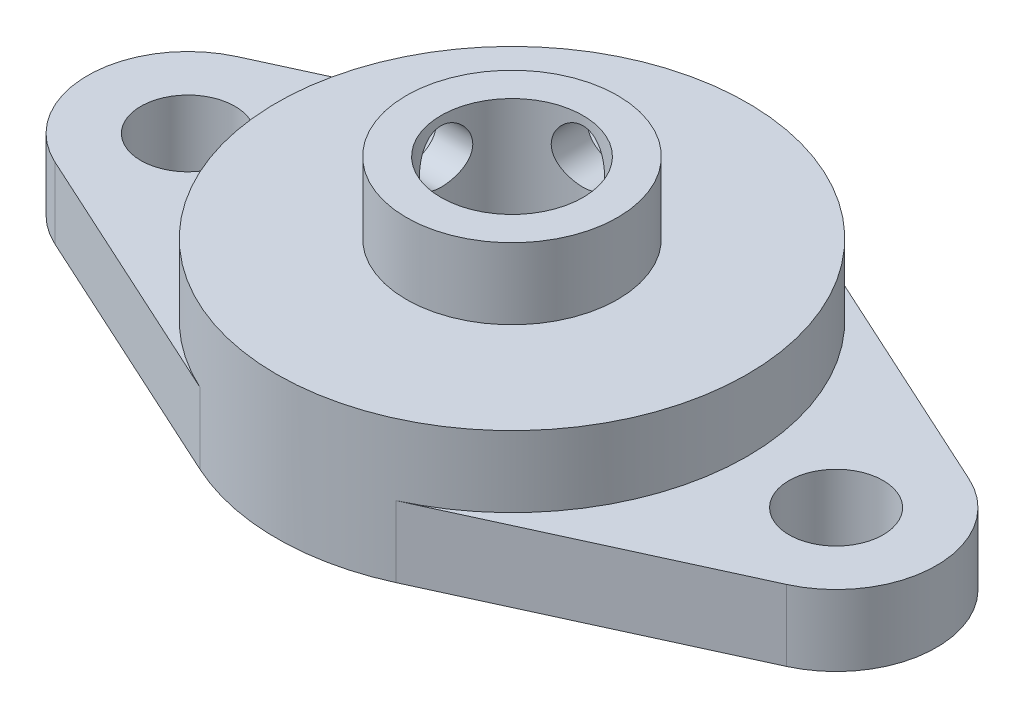
from build123d import *

# Parameters (mm, degrees)
SKETCH_1_R            = 13.25
SKETCH_1_R_2          = 4
EXTRUDE_288_DEPTH     = 8
SKETCH_2_R            = 2.65
EXTRUDE_567_DEPTH     = 4
SKETCH_3_R            = 5.95
SKETCH_3_R_2          = 4
EXTRUDE_693_DEPTH     = 4
SKETCH_4_R            = 1.5
CUT_EXTRUDE_831_DEPTH = 14.25
SKETCH_5_R            = 1.5
CUT_EXTRUDE_2_DEPTH   = 24.9


with BuildPart() as part:
    # 草图1 → Extrude 288 (new body)
    with BuildSketch(Plane(origin=(0, 0, 0), x_dir=(1, 0, 0), z_dir=(0, 1, 0))):
        Circle(SKETCH_1_R)
        Circle(SKETCH_1_R_2, mode=Mode.SUBTRACT)
    extrude(amount=EXTRUDE_288_DEPTH)

    # 草图2 → Extrude 567 (add)
    with BuildSketch(Plane(origin=(0, 0, 0), x_dir=(1, 0, 0), z_dir=(0, 1, 0))):
        with BuildLine():
            Line((-20.602876712, -5.136776341), (-5.517808219, -12.046422392))
            Line((-5.517808219, -12.046422392), (-5.517808219, 12.046422392))
            Line((-5.517808219, 12.046422392), (-20.602876712, 5.136776341))
            ThreePointArc((-20.602876712, 5.136776341), (-23.9, 0), (-20.602876712, -5.136776341))
        make_face()
        with Locations((-18.25, 0)):
            Circle(SKETCH_2_R, mode=Mode.SUBTRACT)
        with BuildLine():
            Line((20.602876712, 5.136776341), (5.517808219, 12.046422392))
            Line((5.517808219, 12.046422392), (5.517808219, -12.046422392))
            Line((5.517808219, -12.046422392), (20.602876712, -5.136776341))
            ThreePointArc((20.602876712, -5.136776341), (23.9, 0), (20.602876712, 5.136776341))
        make_face()
        with Locations((18.25, 0)):
            Circle(SKETCH_2_R, mode=Mode.SUBTRACT)
    extrude(amount=EXTRUDE_567_DEPTH)

    # 草图3 → Extrude 693 (add)
    with BuildSketch(Plane(origin=(0, 8, 0), x_dir=(1, 0, 0), z_dir=(0, 1, 0))):
        Circle(SKETCH_3_R)
        Circle(SKETCH_3_R_2, mode=Mode.SUBTRACT)
    extrude(amount=EXTRUDE_693_DEPTH)

    # 草图4 → Cut-Extrude 831 (cut, through all)
    with BuildSketch(Plane.XY):
        with Locations((0, 10)):
            Circle(SKETCH_4_R)
    extrude(amount=-CUT_EXTRUDE_831_DEPTH, mode=Mode.SUBTRACT)

    # 草图5 → 紧定2 (cut, through all)
    with BuildSketch(Plane(origin=(0, 0, 0), x_dir=(0, 0, -1), z_dir=(1, 0, 0))):
        with Locations((0, 10)):
            Circle(SKETCH_5_R)
    extrude(amount=-CUT_EXTRUDE_2_DEPTH, mode=Mode.SUBTRACT)


solid = part.part
